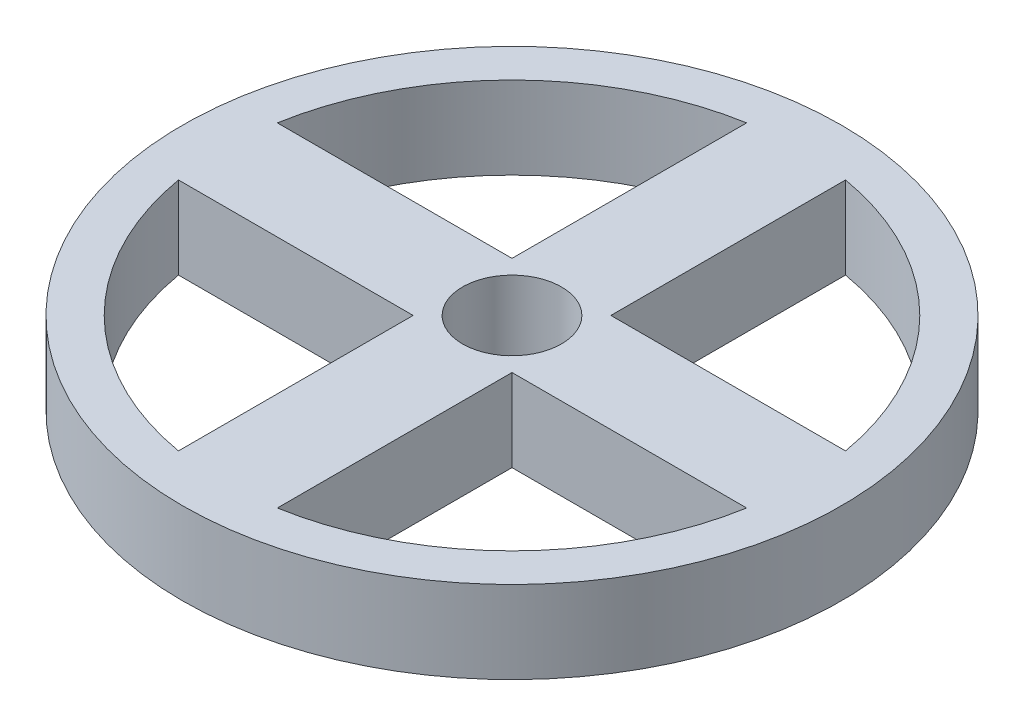
from build123d import *

# Parameters (mm, degrees)
SKETCH1_R           = 40
SKETCH1_R_2         = 35
BOSS_EXTRUDE1_DEPTH = 10


with BuildPart() as part:
    # Sketch1 → Boss-Extrude1 (new body)
    with BuildSketch(Plane(origin=(0, 0, 0), x_dir=(1, 0, 0), z_dir=(0, 1, 0))):
        Circle(SKETCH1_R)
        Circle(SKETCH1_R_2, mode=Mode.SUBTRACT)
        with BuildLine():
            Line((-6, 0), (-6, 6))
            Line((-6, 6), (-34.481879299, 6))
            ThreePointArc((-34.481879299, 6), (-35, 0), (-34.481879299, -6))
            Line((-34.481879299, -6), (-6, -6))
            Line((-6, -6), (-6, 0))
        make_face()
        with BuildLine():
            Line((6, -34.481879299), (6, -6))
            Line((6, -6), (0, -6))
            Line((0, -6), (-6, -6))
            Line((-6, -6), (-6, -34.481879299))
            ThreePointArc((-6, -34.481879299), (0, -35), (6, -34.481879299))
        make_face()
        with BuildLine():
            Line((6, 6), (6, 0))
            Line((6, 0), (6, -6))
            Line((6, -6), (34.481879299, -6))
            ThreePointArc((34.481879299, -6), (34.870229247, -3.011164603), (35, 0))
            ThreePointArc((35, 0), (34.870229247, 3.011164603), (34.481879299, 6))
            Line((34.481879299, 6), (6, 6))
        make_face()
        with BuildLine():
            Line((0, 6), (6, 6))
            Line((6, 6), (6, 34.481879299))
            ThreePointArc((6, 34.481879299), (0, 35), (-6, 34.481879299))
            Line((-6, 34.481879299), (-6, 6))
            Line((-6, 6), (0, 6))
        make_face()
        with BuildLine():
            Line((-6, -6), (0, -6))
            ThreePointArc((0, -6), (-4.242640687, -4.242640687), (-6, 0))
            Line((-6, 0), (-6, -6))
        make_face()
        with BuildLine():
            Line((6, -6), (6, 0))
            ThreePointArc((6, 0), (4.242640687, -4.242640687), (0, -6))
            Line((0, -6), (6, -6))
        make_face()
        with BuildLine():
            ThreePointArc((0, 6), (4.242640687, 4.242640687), (6, 0))
            Line((6, 0), (6, 6))
            Line((6, 6), (0, 6))
        make_face()
        with BuildLine():
            ThreePointArc((-6, 0), (-4.242640687, 4.242640687), (0, 6))
            Line((0, 6), (-6, 6))
            Line((-6, 6), (-6, 0))
        make_face()
    extrude(amount=BOSS_EXTRUDE1_DEPTH)


solid = part.part
